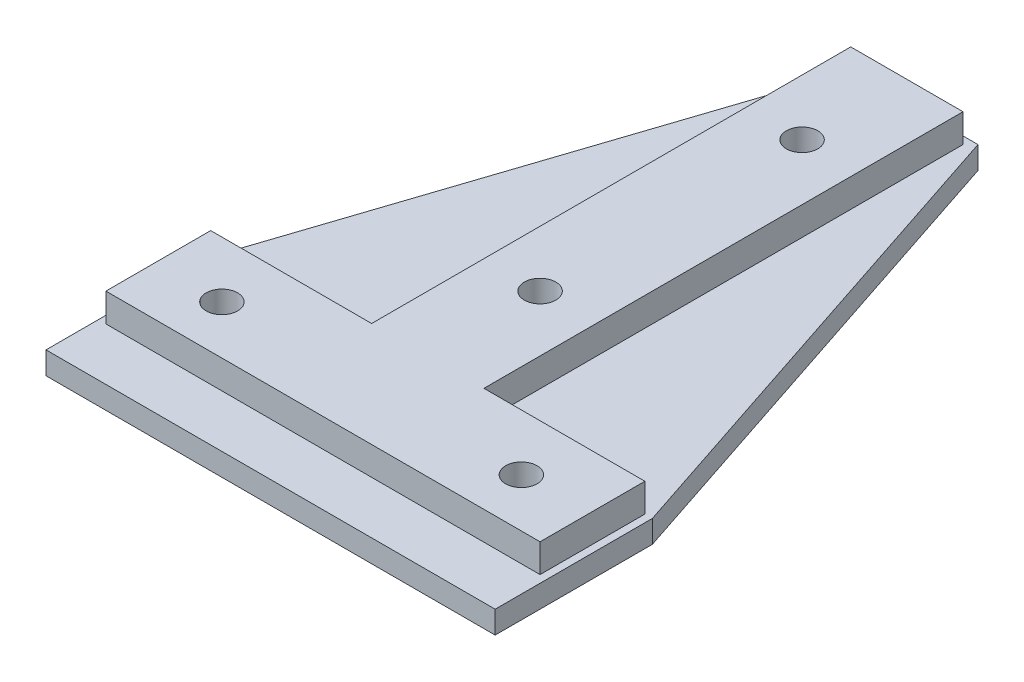
from build123d import *

# Parameters (mm, degrees)
SKETCH1_W           = 17
SKETCH1_H           = 65
SKETCH1_R           = 2.1
SKETCH1_W_2         = 60
SKETCH1_H_2         = 15
SKETCH1_H_3         = 6
BOSS_EXTRUDE1_DEPTH = 3
SKETCH2_W           = 17
SKETCH2_H           = 65
SKETCH2_R           = 2.1
BOSS_EXTRUDE2_DEPTH = 3.8
SKETCH3_R           = 2.1
CUT_EXTRUDE1_DEPTH  = 18.8
CUT_EXTRUDE2_DEPTH  = 3
SKETCH5_W           = 1
SKETCH5_H           = 1
SKETCH5_W_2         = 15
SKETCH5_H_2         = 64
SKETCH5_H_3         = 14
SKETCH5_W_3         = 58
CUT_EXTRUDE3_DEPTH  = 3.8


with BuildPart() as part:
    # Sketch1 → Boss-Extrude1 (new body)
    with BuildSketch(Plane(origin=(0, 0, 0), x_dir=(1, 0, 0), z_dir=(0, 1, 0))):
        Polygon((-8.5, 72.5), (-30, 7.5), (-8.5, 7.5), align=None)
        Polygon((8.5, 7.5), (30, 7.5), (8.5, 72.5), align=None)
        with Locations((0, 40)):
            Rectangle(SKETCH1_W, SKETCH1_H)
        with Locations((0, 22.5)):
            Circle(SKETCH1_R, mode=Mode.SUBTRACT)
        with Locations((0, 57.5)):
            Circle(SKETCH1_R, mode=Mode.SUBTRACT)
        Rectangle(SKETCH1_W_2, SKETCH1_H_2)
        with Locations((-20, 0)):
            Circle(SKETCH1_R, mode=Mode.SUBTRACT)
        with Locations((20, 0)):
            Circle(SKETCH1_R, mode=Mode.SUBTRACT)
        with Locations((0, -10.5)):
            Rectangle(SKETCH1_W_2, SKETCH1_H_3)
        with Locations((0, 57.5)):
            Circle(SKETCH1_R)
        with Locations((0, 22.5)):
            Circle(SKETCH1_R)
        with Locations((-20, 0)):
            Circle(SKETCH1_R)
        with Locations((20, 0)):
            Circle(SKETCH1_R)
    extrude(amount=BOSS_EXTRUDE1_DEPTH)

    # Sketch2 → Boss-Extrude2 (add)
    with BuildSketch(Plane(origin=(0, 3, 0), x_dir=(1, 0, 0), z_dir=(0, 1, 0))):
        with Locations((0, 40)):
            Rectangle(SKETCH2_W, SKETCH2_H)
        with Locations((0, 22.5)):
            Circle(SKETCH2_R, mode=Mode.SUBTRACT)
        with Locations((0, 57.5)):
            Circle(SKETCH2_R, mode=Mode.SUBTRACT)
        Polygon((-8.5, 7.5), (-30, 7.5), (-30, -7.5), (30, -7.5), (30, 7.5), (8.5, 7.5), align=None)
        with Locations((-20, 0)):
            Circle(SKETCH2_R, mode=Mode.SUBTRACT)
        with Locations((20, 0)):
            Circle(SKETCH2_R, mode=Mode.SUBTRACT)
    extrude(amount=BOSS_EXTRUDE2_DEPTH)

    # Sketch3 → Cut-Extrude1 (cut)
    with BuildSketch(Plane(origin=(0, 6.8, 0), x_dir=(1, 0, 0), z_dir=(0, 1, 0))):
        with Locations((0, 57.5)):
            Circle(SKETCH3_R)
        with Locations((0, 22.5)):
            Circle(SKETCH3_R)
        with Locations((20, 0)):
            Circle(SKETCH3_R)
        with Locations((-20, 0)):
            Circle(SKETCH3_R)
    extrude(amount=-CUT_EXTRUDE1_DEPTH, mode=Mode.SUBTRACT)

    # Sketch4 → Cut-Extrude2 (cut)
    with BuildSketch(Plane(origin=(0, 0, 0), x_dir=(-1, 0, 0), z_dir=(0, -1, 0))):
        Polygon((23.6, 2.1), (23.6, -2.1), (20, -4.1), (16.4, -2.1), (16.4, 2.1), (20, 4.1), align=None)
        Polygon((-23.6, 2.1), (-23.6, -2.1), (-20, -4.1), (-16.4, -2.1), (-16.4, 2.1), (-20, 4.1), align=None)
        Polygon((0, 18.4), (3.6, 20.4), (3.6, 24.6), (0, 26.6), (-3.6, 24.6), (-3.6, 20.4), align=None)
        Polygon((3.6, 55.4), (3.6, 59.6), (0, 61.6), (-3.6, 59.6), (-3.6, 55.4), (0, 53.4), align=None)
    extrude(amount=-CUT_EXTRUDE2_DEPTH, mode=Mode.SUBTRACT)

    # Sketch5 → Cut-Extrude3 (cut)
    with BuildSketch(Plane(origin=(0, 6.8, 0), x_dir=(1, 0, 0), z_dir=(0, 1, 0))):
        with Locations((8, 72)):
            Rectangle(SKETCH5_W, SKETCH5_H)
        with Locations((0, 72)):
            Rectangle(SKETCH5_W_2, SKETCH5_H)
        with Locations((-8, 72)):
            Rectangle(SKETCH5_W, SKETCH5_H)
        with Locations((-8, 39.5)):
            Rectangle(SKETCH5_W, SKETCH5_H_2)
        with Locations((8, 39.5)):
            Rectangle(SKETCH5_W, SKETCH5_H_2)
        with Locations((29.5, -7)):
            Rectangle(SKETCH5_W, SKETCH5_H)
        with Locations((-29.5, -7)):
            Rectangle(SKETCH5_W, SKETCH5_H)
        with Locations((-29.5, 0.5)):
            Rectangle(SKETCH5_W, SKETCH5_H_3)
        with Locations((0, -7)):
            Rectangle(SKETCH5_W_3, SKETCH5_H)
        with Locations((29.5, 0.5)):
            Rectangle(SKETCH5_W, SKETCH5_H_3)
    extrude(amount=-CUT_EXTRUDE3_DEPTH, mode=Mode.SUBTRACT)


solid = part.part
